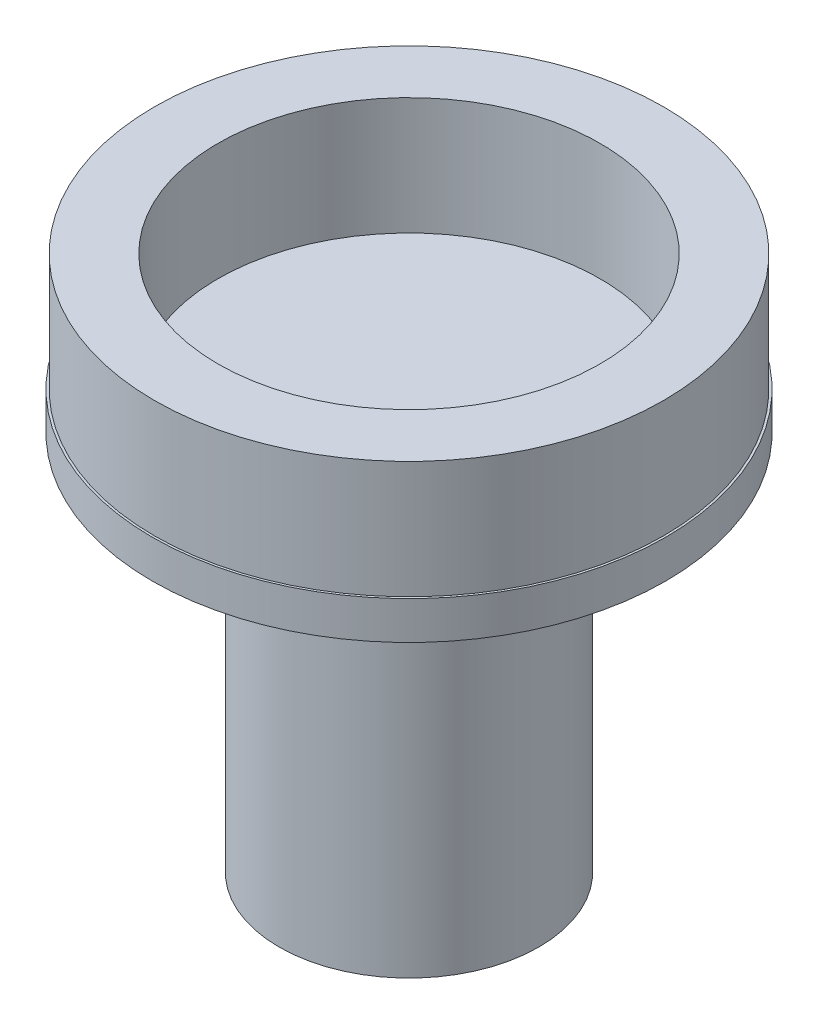
from build123d import *

# Parameters (mm, degrees)
SKETCH1_R           = 4.015
SKETCH1_R_2         = 3.015
BOSS_EXTRUDE1_DEPTH = 1.85
SKETCH2_R           = 4.05
BOSS_EXTRUDE2_DEPTH = 0.6
SKETCH3_R           = 2.05
SKETCH3_R_2         = 1.05
BOSS_EXTRUDE3_DEPTH = 6


with BuildPart() as part:
    # Sketch1 → Boss-Extrude1 (new body)
    with BuildSketch(Plane(origin=(0, 0, 0), x_dir=(1, 0, 0), z_dir=(0, 1, 0))):
        Circle(SKETCH1_R)
        Circle(SKETCH1_R_2, mode=Mode.SUBTRACT)
    extrude(amount=BOSS_EXTRUDE1_DEPTH)

    # Sketch2 → Boss-Extrude2 (add)
    with BuildSketch(Plane(origin=(0, 0, 0), x_dir=(1, 0, 0), z_dir=(0, 1, 0))):
        Circle(SKETCH2_R)
    extrude(amount=-BOSS_EXTRUDE2_DEPTH)

    # Sketch3 → Boss-Extrude3 (add)
    with BuildSketch(Plane.XZ.offset(0.6)):
        Circle(SKETCH3_R)
        Circle(SKETCH3_R_2, mode=Mode.SUBTRACT)
    extrude(amount=BOSS_EXTRUDE3_DEPTH)


solid = part.part
